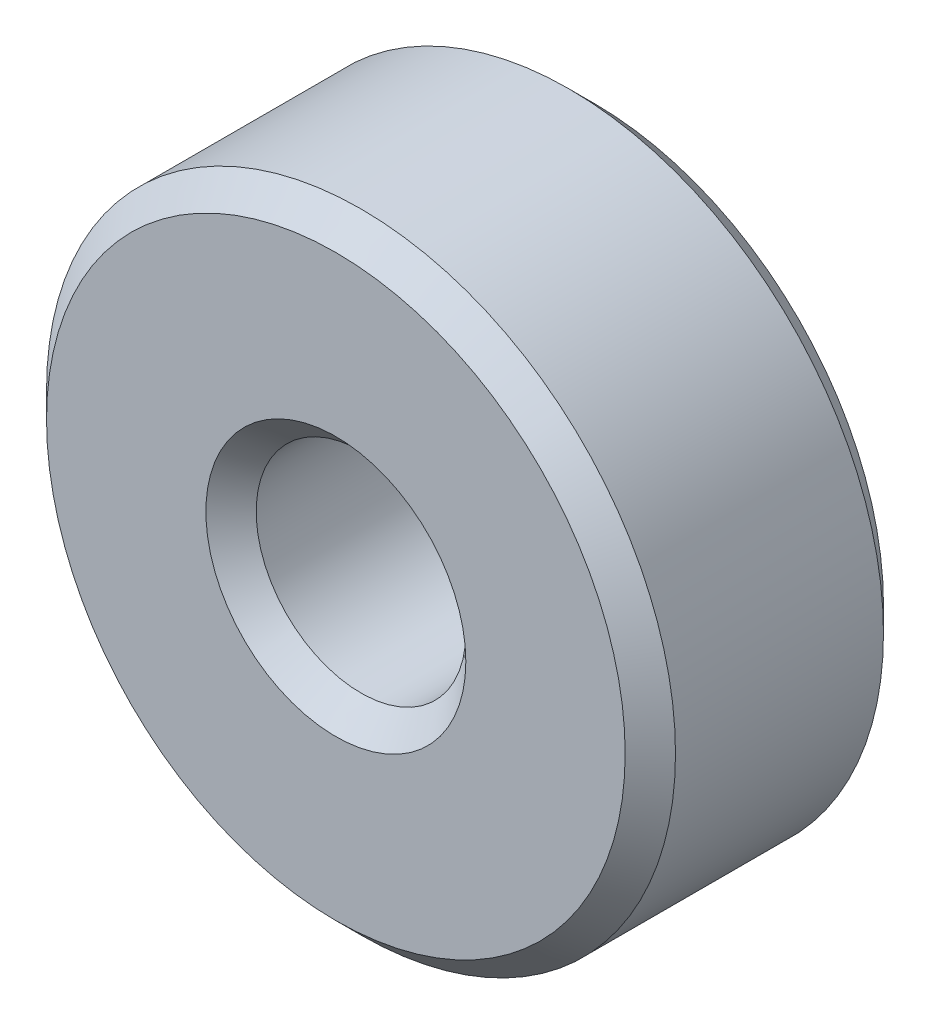
from build123d import *

# Parameters (mm, degrees)
SKETCH1_R           = 4.7625
SKETCH1_R_2         = 1.5875
BOSS_EXTRUDE1_DEPTH = 3.9116
CHAMFER1_SIZE       = 0.381


with BuildPart() as part:
    # Sketch1 → Boss-Extrude1 (new body)
    with BuildSketch(Plane.XY):
        Circle(SKETCH1_R)
        Circle(SKETCH1_R_2, mode=Mode.SUBTRACT)
    extrude(amount=BOSS_EXTRUDE1_DEPTH)

    # Chamfer1
    chamfer1_edges = [part.edges().sort_by_distance(p)[0] for p in [
        (-4.7625, 0, 0),
        (-4.7625, 0, 3.9116),
        (-1.5875, 0, 0),
        (-1.5875, 0, 3.9116),
    ]]
    chamfer(chamfer1_edges, length=CHAMFER1_SIZE)


solid = part.part
